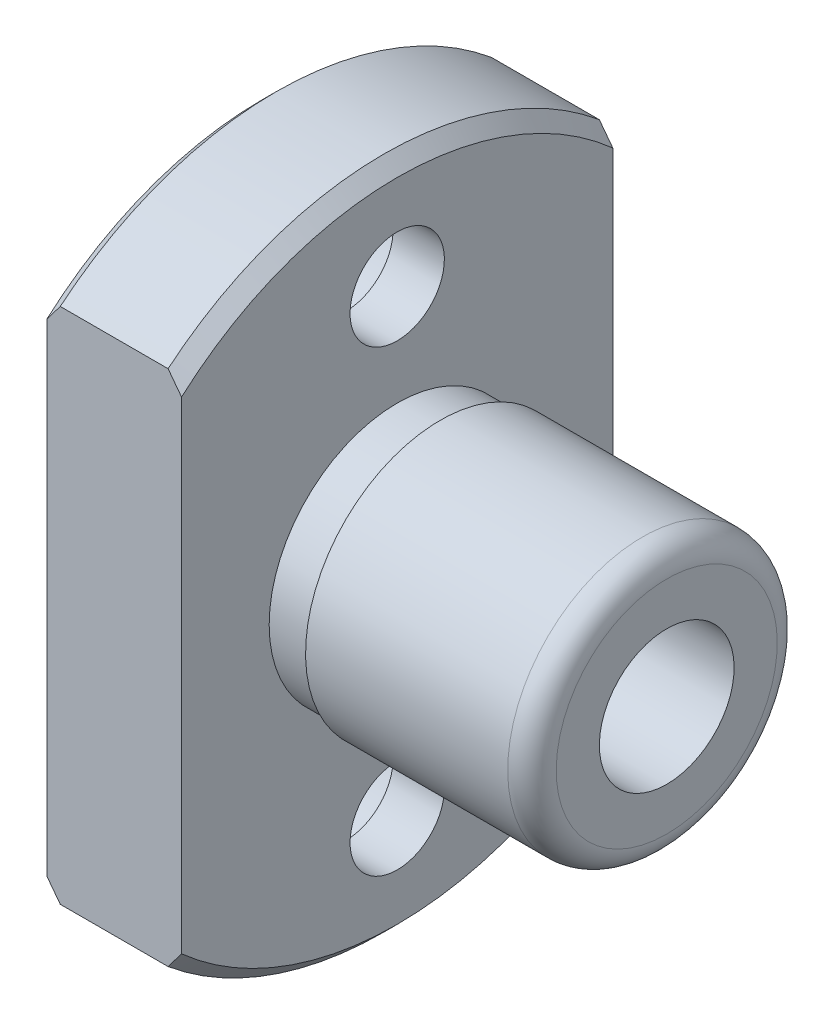
from build123d import *

# Parameters (mm, degrees)
CHAMFER1_SIZE          = 0.5
FILLET1_R              = 0.9
CUT_EXTRUDE2_DEPTH     = 6
CAP_SCREW2_D           = 3.5
CAP_SCREW2_CBORE_D     = 6
CAP_SCREW2_CBORE_DEPTH = 3.1


with BuildPart() as part:
    # Sketch1 → Revolve1 (revolve)
    with BuildSketch(Plane.XY):
        Polygon((-5, 2.5), (10, 2.5), (10, 5), (1.6, 5), (1.6, 4.75), (0, 4.75), (0, 12.5), (-5, 12.5), align=None)
    revolve(axis=Axis((-5, 0, 0), (1, 0, 0)))

    # Chamfer1
    chamfer1_edges = [part.edges().sort_by_distance(p)[0] for p in [
        (0, -12.5, 0),
        (-5, -12.5, 0),
    ]]
    chamfer(chamfer1_edges, length=CHAMFER1_SIZE)

    # Fillet1
    fillet1_edges = [part.edges().sort_by_distance(p)[0] for p in [
        (10, -5, 0),
    ]]
    fillet(fillet1_edges, radius=FILLET1_R)

    # Sketch5 → Cut-Extrude2 (cut, through all)
    with BuildSketch(Plane.ZY):
        with BuildLine():
            Line((-8, 9.604686356), (-8, -9.604686356))
            ThreePointArc((-8, -9.604686356), (-12.5, 0), (-8, 9.604686356))
        make_face()
        with BuildLine():
            Line((8, 9.604686356), (8, -9.604686356))
            ThreePointArc((8, -9.604686356), (12.5, 0), (8, 9.604686356))
        make_face()
    extrude(amount=CUT_EXTRUDE2_DEPTH, mode=Mode.SUBTRACT)

    # Cap Screw2 (through all)
    with Locations(Plane.ZY.offset(5)):
        with Locations((0, -8.5), (0, 8.5)):
            CounterBoreHole(CAP_SCREW2_D / 2, CAP_SCREW2_CBORE_D / 2, CAP_SCREW2_CBORE_DEPTH)


solid = part.part
